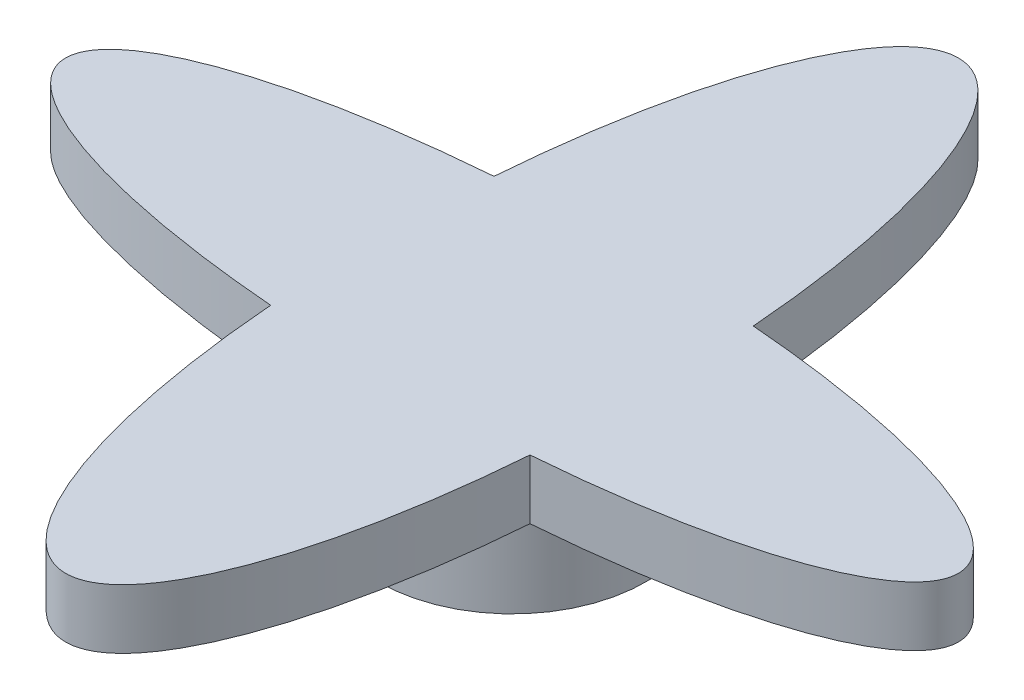
from build123d import *

# Parameters (mm, degrees)
SKETCH1_R           = 4.5
BOSS_EXTRUDE1_DEPTH = 3.5
BOSS_EXTRUDE2_DEPTH = 2


with BuildPart() as part:
    # Sketch1 → Boss-Extrude1 (new body)
    with BuildSketch(Plane(origin=(0, 0, 0), x_dir=(1, 0, 0), z_dir=(0, 1, 0))):
        Circle(SKETCH1_R)
    extrude(amount=BOSS_EXTRUDE1_DEPTH)

    # Sketch2 → Boss-Extrude2 (add)
    with BuildSketch(Plane(origin=(0, 3.5, 0), x_dir=(1, 0, 0), z_dir=(0, 1, 0))):
        with BuildLine():
            add(Edge.make_bspline(
                [(-4.356928926, 3.752288679), (-51.641879819, 0), (-4.356928926, -3.752288679)],
                knots=[5.007098524, 5.007098524, 5.007098524, 7.559272091, 7.559272091, 7.559272091], degree=2, weights=[1, 0.290461928, 1]))
            add(Edge.make_bspline(
                [(-4.356928926, -3.752288679), (-3.485117738, -15), (0, -15), (3.485117738, -15), (4.356928926, -3.752288679)],
                knots=[1.823634168, 1.823634168, 1.823634168, 3.141592654, 3.141592654, 4.45955114, 4.45955114, 4.45955114], degree=2, weights=[1, 0.790617663, 1, 0.790617663, 1]))
            add(Edge.make_bspline(
                [(4.356928926, -3.752288679), (51.641879819, 0), (4.356928926, 3.752288679)],
                knots=[1.86550587, 1.86550587, 1.86550587, 4.417679437, 4.417679437, 4.417679437], degree=2, weights=[1, 0.290461928, 1]))
            add(Edge.make_bspline(
                [(4.356928926, 3.752288679), (3.485117738, 15), (0, 15), (-3.485117738, 15), (-4.356928926, 3.752288679)],
                knots=[4.965226821, 4.965226821, 4.965226821, 6.283185307, 6.283185307, 7.601143793, 7.601143793, 7.601143793], degree=2, weights=[1, 0.790617663, 1, 0.790617663, 1]))
        make_face()
    extrude(amount=BOSS_EXTRUDE2_DEPTH)


solid = part.part
